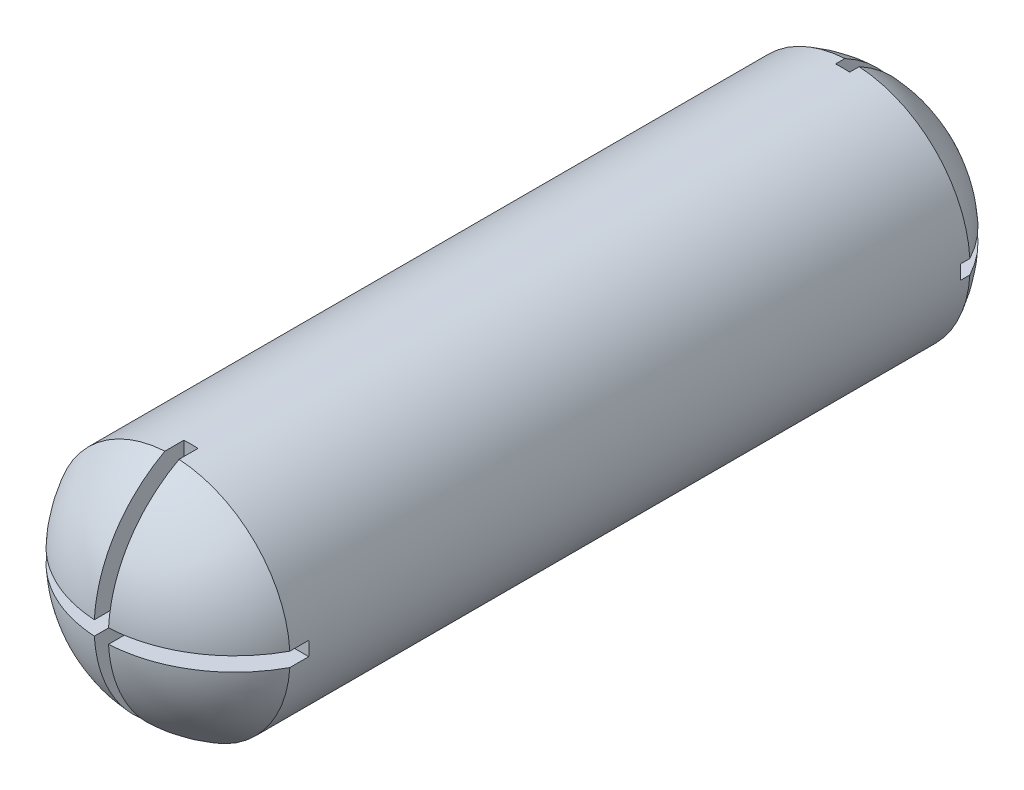
from build123d import *

# Parameters (mm, degrees)
SKETCH1_R               = 25
BOSS_EXTRUDE1_DEPTH     = 144
DOME1_FACE_RADIUS       = 25
DOME1_HEIGHT            = 15
DOME2_FACE_RADIUS       = 25
DOME2_HEIGHT            = 15
CUT_EXTRUDE3_DEPTH      = 2
CUT_EXTRUDE3_DEPTH_BACK = 20
SKETCH3_W               = 3
SKETCH3_H               = 25.725601723
SKETCH3_W_2             = 25.013024677
SKETCH3_H_2             = 3
CUT_EXTRUDE4_DEPTH      = 30


with BuildPart() as part:
    # Sketch1 → Boss-Extrude1 (new body)
    with BuildSketch(Plane.XY):
        Circle(SKETCH1_R)
    extrude(amount=BOSS_EXTRUDE1_DEPTH)

    # Dome1: a dome of height H over a round flat face of radius A is a cap of a sphere of radius (A * A + H * H) / (2 * H)
    dome1_r = (DOME1_FACE_RADIUS * DOME1_FACE_RADIUS + DOME1_HEIGHT * DOME1_HEIGHT) / (2 * DOME1_HEIGHT)
    dome1_base = Plane((0, 0, 144), z_dir=(0, 0, 1))
    with Locations(dome1_base.offset(DOME1_HEIGHT - dome1_r)):
        dome1_ball = Sphere(dome1_r, mode=Mode.PRIVATE)
    add(split(dome1_ball, bisect_by=dome1_base, keep=Keep.TOP, mode=Mode.PRIVATE))

    # Dome2: a dome of height H over a round flat face of radius A is a cap of a sphere of radius (A * A + H * H) / (2 * H)
    dome2_r = (DOME2_FACE_RADIUS * DOME2_FACE_RADIUS + DOME2_HEIGHT * DOME2_HEIGHT) / (2 * DOME2_HEIGHT)
    dome2_base = Plane((0, 0, 0), z_dir=(0, 0, -1))
    with Locations(dome2_base.offset(DOME2_HEIGHT - dome2_r)):
        dome2_ball = Sphere(dome2_r, mode=Mode.PRIVATE)
    add(split(dome2_ball, bisect_by=dome2_base, keep=Keep.TOP, mode=Mode.PRIVATE))

    # Sketch2 → Cut-Extrude3 (cut, two sides)
    with BuildSketch(Plane.XY) as cut_extrude3_sk:
        with BuildLine():
            Line((-1.5, 24.954959427), (-1.5, 1.5))
            Line((-1.5, 1.5), (-24.954959427, 1.5))
            ThreePointArc((-24.954959427, 1.5), (-25, 0), (-24.954959427, -1.5))
            Line((-24.954959427, -1.5), (-1.5, -1.5))
            Line((-1.5, -1.5), (-1.5, -24.954959427))
            ThreePointArc((-1.5, -24.954959427), (0, -25), (1.5, -24.954959427))
            Line((1.5, -24.954959427), (1.5, -1.5))
            Line((1.5, -1.5), (24.954959427, -1.5))
            ThreePointArc((24.954959427, -1.5), (24.98873732, -0.750338033), (25, 0))
            ThreePointArc((25, 0), (24.98873732, 0.750338033), (24.954959427, 1.5))
            Line((24.954959427, 1.5), (1.5, 1.5))
            Line((1.5, 1.5), (1.5, 24.954959427))
            ThreePointArc((1.5, 24.954959427), (0, 25), (-1.5, 24.954959427))
        make_face()
    extrude(amount=CUT_EXTRUDE3_DEPTH, mode=Mode.SUBTRACT)
    extrude(cut_extrude3_sk.sketch, amount=-CUT_EXTRUDE3_DEPTH_BACK, mode=Mode.SUBTRACT)

    # Sketch3 → Cut-Extrude4 (cut)
    with BuildSketch(Plane.XY.offset(170)):
        with Locations((0, -14.362800862)):
            Rectangle(SKETCH3_W, SKETCH3_H)
        with Locations((0, 14.362800862)):
            Rectangle(SKETCH3_W, SKETCH3_H)
        with Locations((14.006512339, 0)):
            Rectangle(SKETCH3_W_2, SKETCH3_H_2)
        with Locations((-14.006512339, 0)):
            Rectangle(SKETCH3_W_2, SKETCH3_H_2)
        Rectangle(SKETCH3_W, SKETCH3_H_2)
    extrude(amount=-CUT_EXTRUDE4_DEPTH, mode=Mode.SUBTRACT)


solid = part.part
